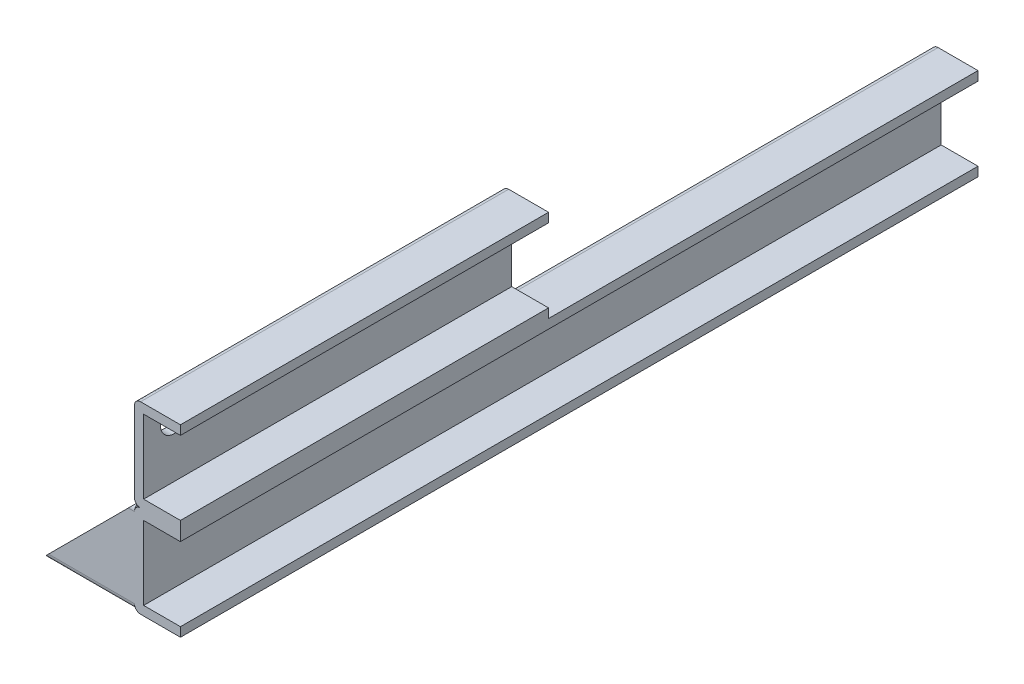
from build123d import *

# Parameters (mm, degrees)
SALIENTE_EXTRUIR1_DEPTH = 130
REDONDEO1_R             = 2
SALIENTE_EXTRUIR2_DEPTH = 120
CROQUIS3_R              = 4.5
CORTAR_EXTRUIR1_DEPTH   = 20
CROQUIS4_W              = 24
CROQUIS4_H              = 24
SALIENTE_EXTRUIR3_DEPTH = 30
CORTAR_EXTRUIR2_DEPTH   = 50


with BuildPart() as part:
    # Croquis1 → Saliente-Extruir1 (new body, symmetric)
    with BuildSketch(Plane.XY):
        Polygon((-12, 12), (0, 12), (0, 15), (-15, 15), (-15, -15), (0, -15), (0, -12), (-12, -12), align=None)
    extrude(amount=SALIENTE_EXTRUIR1_DEPTH, both=True)

    # Redondeo1
    redondeo1_edges = [part.edges().sort_by_distance(p)[0] for p in [
        (-15, 15, 0),
        (-15, -15, 0),
    ]]
    fillet(redondeo1_edges, radius=REDONDEO1_R)

    # Croquis2 → Saliente-Extruir2 (add)
    with BuildSketch(Plane.XY.offset(130)):
        with BuildLine():
            Line((-15, 43), (-15, 17))
            ThreePointArc((-15, 17), (-14.414213562, 15.585786438), (-13, 15))
            Line((-13, 15), (0, 15))
            Line((0, 15), (0, 18))
            Line((0, 18), (-12, 18))
            Line((-12, 18), (-12, 42))
            Line((-12, 42), (0, 42))
            Line((0, 42), (0, 45))
            Line((0, 45), (-13, 45))
            ThreePointArc((-13, 45), (-14.414213562, 44.414213562), (-15, 43))
        make_face()
    extrude(amount=-SALIENTE_EXTRUIR2_DEPTH)

    # Croquis3 → Cortar-Extruir1 (cut)
    with BuildSketch(Plane.ZY.offset(15)):
        with Locations((120, 36)):
            Circle(CROQUIS3_R)
        with Locations((20, 36)):
            Circle(CROQUIS3_R)
    extrude(amount=-CORTAR_EXTRUIR1_DEPTH, mode=Mode.SUBTRACT)

    # Croquis4 → Saliente-Extruir3 (add)
    with BuildSketch(Plane.ZY.offset(15)):
        with BuildLine():
            Line((128, -15), (102, -15))
            ThreePointArc((102, -15), (100.585786438, -14.414213562), (100, -13))
            Line((100, -13), (100, 13))
            ThreePointArc((100, 13), (100.585786438, 14.414213562), (102, 15))
            Line((102, 15), (128, 15))
            ThreePointArc((128, 15), (129.414213562, 14.414213562), (130, 13))
            Line((130, 13), (130, -13))
            ThreePointArc((130, -13), (129.414213562, -14.414213562), (128, -15))
        make_face()
        with Locations((115, 0)):
            Rectangle(CROQUIS4_W, CROQUIS4_H, mode=Mode.SUBTRACT)
    extrude(amount=SALIENTE_EXTRUIR3_DEPTH)

    # Croquis5 → Cortar-Extruir2 (cut)
    with BuildSketch(Plane.XY.offset(130)):
        Polygon((-45, -15), (-15, 15), (-45, 15), align=None)
    extrude(amount=-CORTAR_EXTRUIR2_DEPTH, mode=Mode.SUBTRACT)


solid = part.part
